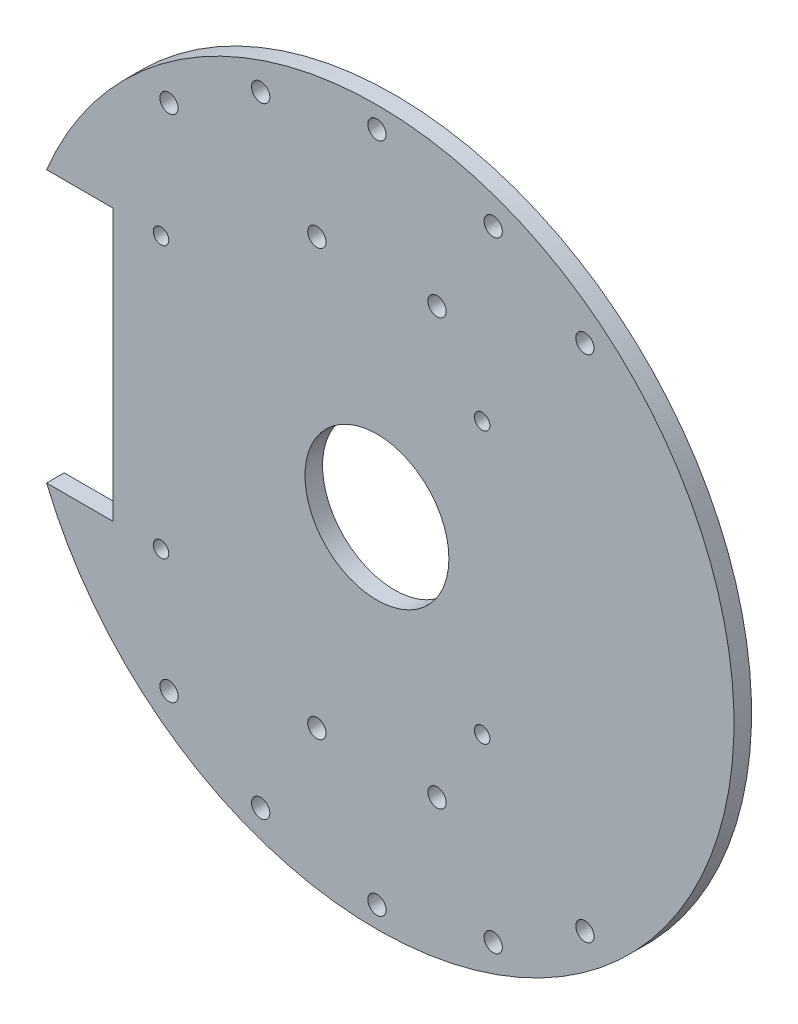
from build123d import *

# Parameters (mm, degrees)
SKETCH1_R           = 64.5
SKETCH1_R_2         = 1.65
SKETCH1_R_3         = 13
SKETCH1_R_4         = 1.4
BOSS_EXTRUDE2_DEPTH = 3.175
CUT_EXTRUDE1_DEPTH  = 3.175


with BuildPart() as part:
    # Sketch1 → Boss-Extrude2 (new body)
    with BuildSketch(Plane(origin=(0, 0, 0), x_dir=(-1, 0, 0), z_dir=(0, 0, 1))):
        with Locations((15.168596538, 0.366425758)):
            Circle(SKETCH1_R)
        with Locations((15.168596538, -60.283574242)):
            Circle(SKETCH1_R_2, mode=Mode.SUBTRACT)
        with Locations((15.168596538, 61.016425758)):
            Circle(SKETCH1_R_2, mode=Mode.SUBTRACT)
        with Locations((26.018596538, -38.058574242)):
            Circle(SKETCH1_R_2, mode=Mode.SUBTRACT)
        with Locations((4.318596538, -38.058574242)):
            Circle(SKETCH1_R_2, mode=Mode.SUBTRACT)
        with Locations((26.018596538, 38.791425758)):
            Circle(SKETCH1_R_2, mode=Mode.SUBTRACT)
        with Locations((4.318596538, 38.791425758)):
            Circle(SKETCH1_R_2, mode=Mode.SUBTRACT)
        with Locations((15.168596538, 0.366425758)):
            Circle(SKETCH1_R_3, mode=Mode.SUBTRACT)
        with Locations((54.168596538, -24.133574242)):
            Circle(SKETCH1_R_4, mode=Mode.SUBTRACT)
        with Locations((54.168596538, 24.866425758)):
            Circle(SKETCH1_R_4, mode=Mode.SUBTRACT)
        with Locations((-3.831403462, -24.133574242)):
            Circle(SKETCH1_R_4, mode=Mode.SUBTRACT)
        with Locations((-3.831403462, 24.866425758)):
            Circle(SKETCH1_R_4, mode=Mode.SUBTRACT)
        with Locations((-5.831403462, 56.366425758)):
            Circle(SKETCH1_R_2, mode=Mode.SUBTRACT)
        with Locations((-22.394874657, 46.366425758)):
            Circle(SKETCH1_R_2, mode=Mode.SUBTRACT)
        with Locations((36.168596538, 56.366425758)):
            Circle(SKETCH1_R_2, mode=Mode.SUBTRACT)
        with Locations((52.732067734, 46.366425758)):
            Circle(SKETCH1_R_2, mode=Mode.SUBTRACT)
        with Locations((52.732067734, -45.633574242)):
            Circle(SKETCH1_R_2, mode=Mode.SUBTRACT)
        with Locations((36.168596538, -55.633574242)):
            Circle(SKETCH1_R_2, mode=Mode.SUBTRACT)
        with Locations((-5.831403462, -55.633574242)):
            Circle(SKETCH1_R_2, mode=Mode.SUBTRACT)
        with Locations((-22.394874657, -45.633574242)):
            Circle(SKETCH1_R_2, mode=Mode.SUBTRACT)
    extrude(amount=BOSS_EXTRUDE2_DEPTH)

    # Sketch2 → Cut-Extrude1 (cut)
    with BuildSketch(Plane.XY.offset(3.175)):
        with BuildLine():
            Line((-74.834332099, 24.133574242), (-62.834332099, 24.133574242))
            Line((-62.834332099, 24.133574242), (-62.834332099, -24.866425758))
            Line((-62.834332099, -24.866425758), (-74.834332099, -24.866425758))
            ThreePointArc((-74.834332099, -24.866425758), (-79.668596538, -0.366425758), (-74.834332099, 24.133574242))
        make_face()
    extrude(amount=-CUT_EXTRUDE1_DEPTH, mode=Mode.SUBTRACT)


solid = part.part
